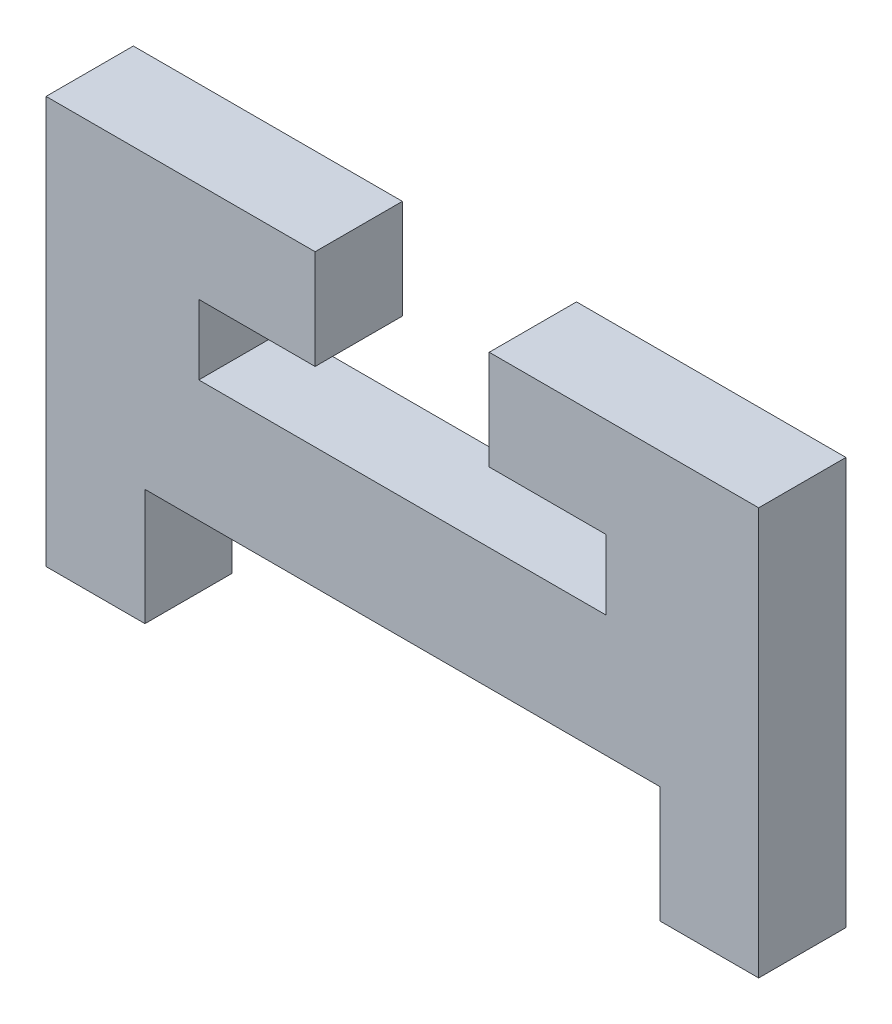
from build123d import *

# Parameters (mm, degrees)
SALIENTE_EXTRUIR1_DEPTH = 3


with BuildPart() as part:
    # Model → Saliente-Extruir1 (new body)
    with BuildSketch(Plane.XY):
        Polygon((38.05, 7.7), (41.45, 7.7), (41.45, 21.7), (32.186385402, 21.7), (32.186385402, 18.282683294), (36.2, 18.282683294), (36.2, 15.882683294), (29.7, 15.882683294), (22.2, 15.882683294), (22.2, 18.282683294), (26.2, 18.282683294), (26.2, 21.7), (16.95, 21.7), (16.95, 7.7), (20.35, 7.7), (20.35, 11.7), (38.05, 11.7), align=None)
    extrude(amount=SALIENTE_EXTRUIR1_DEPTH)


solid = part.part
